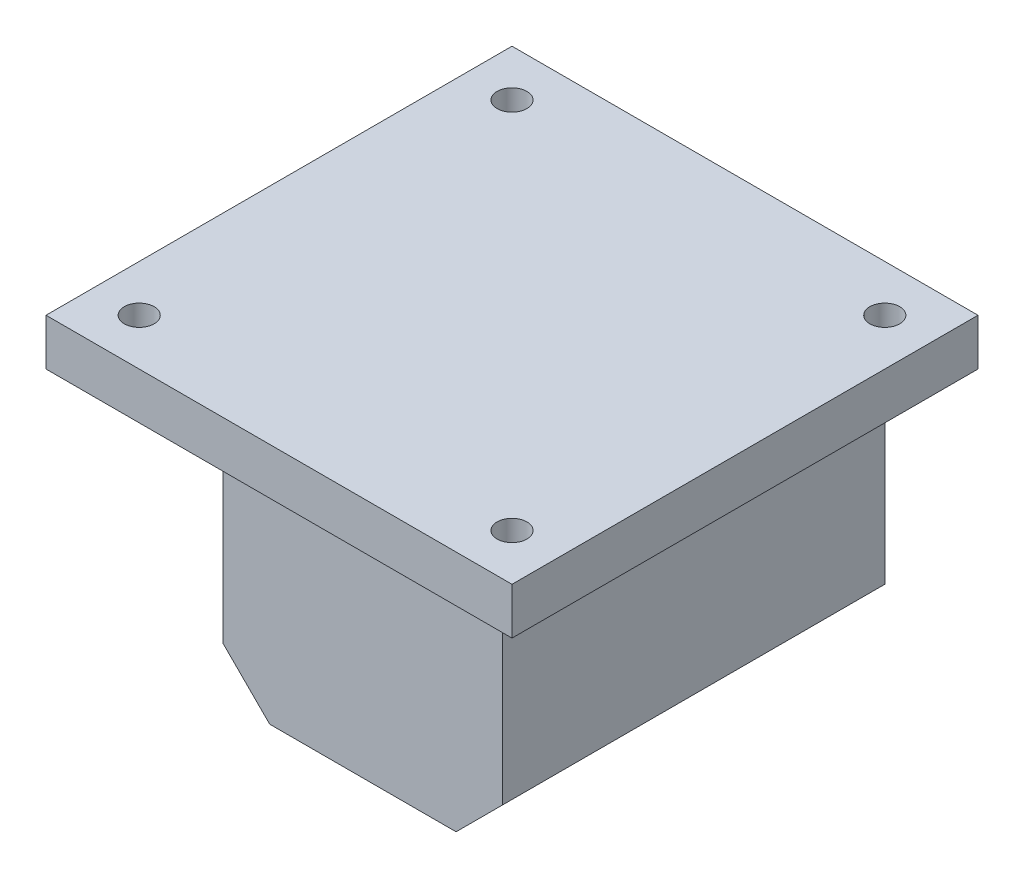
from build123d import *

# Parameters (mm, degrees)
SKETCH1_W           = 30
SKETCH1_H           = 30
SKETCH1_R           = 2.65
BOSS_EXTRUDE1_DEPTH = 31
SKETCH2_W           = 30
SKETCH2_H           = 30
BOSS_EXTRUDE2_DEPTH = 10
BOSS_EXTRUDE3_DEPTH = 5
CHAMFER1_SIZE       = 5
CUT_EXTRUDE1_REACH  = 37
SKETCH4_R           = 1.6


with BuildPart() as part:
    # Sketch1 → Boss-Extrude1 (new body)
    with BuildSketch(Plane.XY):
        Rectangle(SKETCH1_W, SKETCH1_H)
        Circle(SKETCH1_R, mode=Mode.SUBTRACT)
    extrude(amount=BOSS_EXTRUDE1_DEPTH)

    # Sketch2 → Boss-Extrude2 (add)
    with BuildSketch(Plane.XY.offset(31)):
        Rectangle(SKETCH2_W, SKETCH2_H)
    extrude(amount=BOSS_EXTRUDE2_DEPTH)

    # Sketch3 → Boss-Extrude3 (add)
    with BuildSketch(Plane(origin=(0, 15, 0), x_dir=(1, 0, 0), z_dir=(0, 1, 0))):
        Polygon((0, 0), (-25, 0), (-25, -50), (25, -50), (25, 0), align=None)
    extrude(amount=BOSS_EXTRUDE3_DEPTH)

    # Chamfer1
    chamfer1_edges = [part.edges().sort_by_distance(p)[0] for p in [
        (15, -15, 20.5),
        (-15, -15, 20.5),
    ]]
    chamfer(chamfer1_edges, length=CHAMFER1_SIZE)

    # Sketch4 → Cut-Extrude1 (cut, up to next)
    with BuildSketch(Plane(origin=(0, 20, 0), x_dir=(1, 0, 0), z_dir=(0, 1, 0)), mode=Mode.PRIVATE) as cut_extrude1_sk1:
        with Locations((-20, -5)):
            Circle(SKETCH4_R)
    cut_extrude1_tool1 = extrude(cut_extrude1_sk1.sketch, amount=-CUT_EXTRUDE1_REACH, mode=Mode.PRIVATE) & part.part
    add(cut_extrude1_tool1.solids().sort_by_distance((-20, 20, 5))[0], mode=Mode.SUBTRACT)
    # Sketch4 → Cut-Extrude1 (cut, up to next)
    with BuildSketch(Plane(origin=(0, 20, 0), x_dir=(1, 0, 0), z_dir=(0, 1, 0)), mode=Mode.PRIVATE) as cut_extrude1_sk2:
        with Locations((20, -5)):
            Circle(SKETCH4_R)
    cut_extrude1_tool2 = extrude(cut_extrude1_sk2.sketch, amount=-CUT_EXTRUDE1_REACH, mode=Mode.PRIVATE) & part.part
    add(cut_extrude1_tool2.solids().sort_by_distance((20, 20, 5))[0], mode=Mode.SUBTRACT)
    # Sketch4 → Cut-Extrude1 (cut, up to next)
    with BuildSketch(Plane(origin=(0, 20, 0), x_dir=(1, 0, 0), z_dir=(0, 1, 0)), mode=Mode.PRIVATE) as cut_extrude1_sk3:
        with Locations((20, -45)):
            Circle(SKETCH4_R)
    cut_extrude1_tool3 = extrude(cut_extrude1_sk3.sketch, amount=-CUT_EXTRUDE1_REACH, mode=Mode.PRIVATE) & part.part
    add(cut_extrude1_tool3.solids().sort_by_distance((20, 20, 45))[0], mode=Mode.SUBTRACT)
    # Sketch4 → Cut-Extrude1 (cut, up to next)
    with BuildSketch(Plane(origin=(0, 20, 0), x_dir=(1, 0, 0), z_dir=(0, 1, 0)), mode=Mode.PRIVATE) as cut_extrude1_sk4:
        with Locations((-20, -45)):
            Circle(SKETCH4_R)
    cut_extrude1_tool4 = extrude(cut_extrude1_sk4.sketch, amount=-CUT_EXTRUDE1_REACH, mode=Mode.PRIVATE) & part.part
    add(cut_extrude1_tool4.solids().sort_by_distance((-20, 20, 45))[0], mode=Mode.SUBTRACT)


solid = part.part
